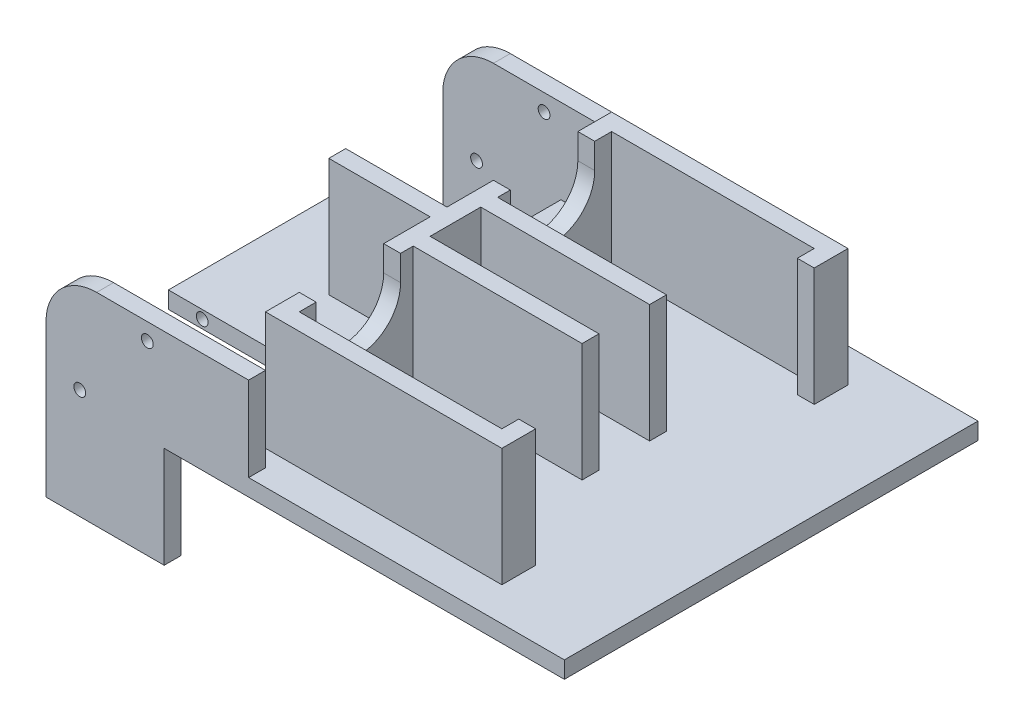
from build123d import *

# Parameters (mm, degrees)
EXTRUDE_1_DEPTH      = 1
SKETCH_2_W           = 7
SKETCH_2_H           = 1
EXTRUDE_2_DEPTH      = 6
EXTRUDE_2_DEPTH_BACK = 6
FILLET_1_R           = 3
SKETCH_3_R           = 0.35
CUT_EXTRUDE_1_DEPTH  = 25.5
SKETCH_4_W           = 1
SKETCH_4_H           = 5
EXTRUDE_3_DEPTH      = 5
EXTRUDE_4_DEPTH      = 7
CUT_EXTRUDE_2_DEPTH  = 7


with BuildPart() as part:
    # 草图1 → 凸台-拉伸1 (new body)
    with BuildSketch(Plane(origin=(0, 0, 0), x_dir=(1, 0, 0), z_dir=(0, 1, 0))):
        Polygon((-12.5, 12.25), (11.2, 12.25), (11.2, -12.25), (-12.5, -12.25), (-19.5, -12.25), (-19.5, -11.25), (-12.5, -11.25), (-12.5, -5), (-19.5, -5), (-19.5, 5), (-12.5, 5), (-12.5, 11.25), (-19.5, 11.25), (-19.5, 12.25), align=None)
    extrude(amount=EXTRUDE_1_DEPTH)

    # 草图2 → 凸台-拉伸2 (add, two sides)
    with BuildSketch(Plane.XZ) as extrude_2_sk:
        with Locations((-16, 11.75)):
            Rectangle(SKETCH_2_W, SKETCH_2_H)
        with Locations((-16, -11.75)):
            Rectangle(SKETCH_2_W, SKETCH_2_H)
    extrude(amount=EXTRUDE_2_DEPTH)
    extrude(extrude_2_sk.sketch, amount=-EXTRUDE_2_DEPTH_BACK)

    # 圆角1
    fillet_1_edges = [part.edges().sort_by_distance(p)[0] for p in [
        (-19.5, 6, 11.75),
        (-19.5, 6, -11.75),
    ]]
    fillet(fillet_1_edges, radius=FILLET_1_R)

    # 草图3 → 切除-拉伸1 (cut, through all)
    with BuildSketch(Plane.XY.offset(12.25)):
        with Locations((-17.5, 0.5)):
            Circle(SKETCH_3_R)
        with Locations((-13.5, 5)):
            Circle(SKETCH_3_R)
    extrude(amount=-CUT_EXTRUDE_1_DEPTH, mode=Mode.SUBTRACT)

    # 草图4 → 凸台-拉伸3 (add)
    with BuildSketch(Plane(origin=(-12.5, 0, 0), x_dir=(0, 0, -1), z_dir=(1, 0, 0))):
        with Locations((-11.75, 3.5)):
            Rectangle(SKETCH_4_W, SKETCH_4_H)
        with Locations((11.75, 3.5)):
            Rectangle(SKETCH_4_W, SKETCH_4_H)
    extrude(amount=EXTRUDE_3_DEPTH)

    # 草图5 → 凸台-拉伸4 (add)
    with BuildSketch(Plane(origin=(0, 1, 0), x_dir=(1, 0, 0), z_dir=(0, 1, 0))):
        Polygon((-8.5, -8.25), (-8.5, -10.25), (5.5, -10.25), (5.5, -8.25), (4.5, -8.25), (4.5, -9.25), (-7.5, -9.25), (-7.5, -8.25), (-7.5, -3.5), (-7.5, -2.5), (2.5, -2.5), (2.5, -1.5), (-7.5, -1.5), (-7.5, 1.5), (2.5, 1.5), (2.5, 2.5), (-7.5, 2.5), (-7.5, 3.5), (-7.5, 8.25), (-7.5, 9.25), (4.5, 9.25), (4.5, 8.25), (5.5, 8.25), (5.5, 10.25), (-8.5, 10.25), (-8.5, 8.25), (-8.5, 3.742436738), (-8.5, 0.5), (-14.5, 0.5), (-14.5, -0.5), (-8.5, -0.5), (-8.5, -3.5), align=None)
    extrude(amount=EXTRUDE_4_DEPTH)

    # 草图6 → 切除-拉伸2 (cut)
    with BuildSketch(Plane.ZY.offset(8.5)):
        with BuildLine():
            Line((-8.25, 6.5), (-8.25, 9.621499742))
            Line((-8.25, 9.621499742), (-3.25, 9.621499742))
            Line((-3.25, 9.621499742), (-3.25, 6.5))
            ThreePointArc((-3.25, 6.5), (-5.75, 4), (-8.25, 6.5))
        make_face()
        with BuildLine():
            Line((3.25, 6.5), (3.25, 9.830182827))
            Line((3.25, 9.830182827), (8.25, 9.830182827))
            Line((8.25, 9.830182827), (8.25, 6.5))
            ThreePointArc((8.25, 6.5), (5.75, 4), (3.25, 6.5))
        make_face()
    extrude(amount=-CUT_EXTRUDE_2_DEPTH, mode=Mode.SUBTRACT)


solid = part.part
